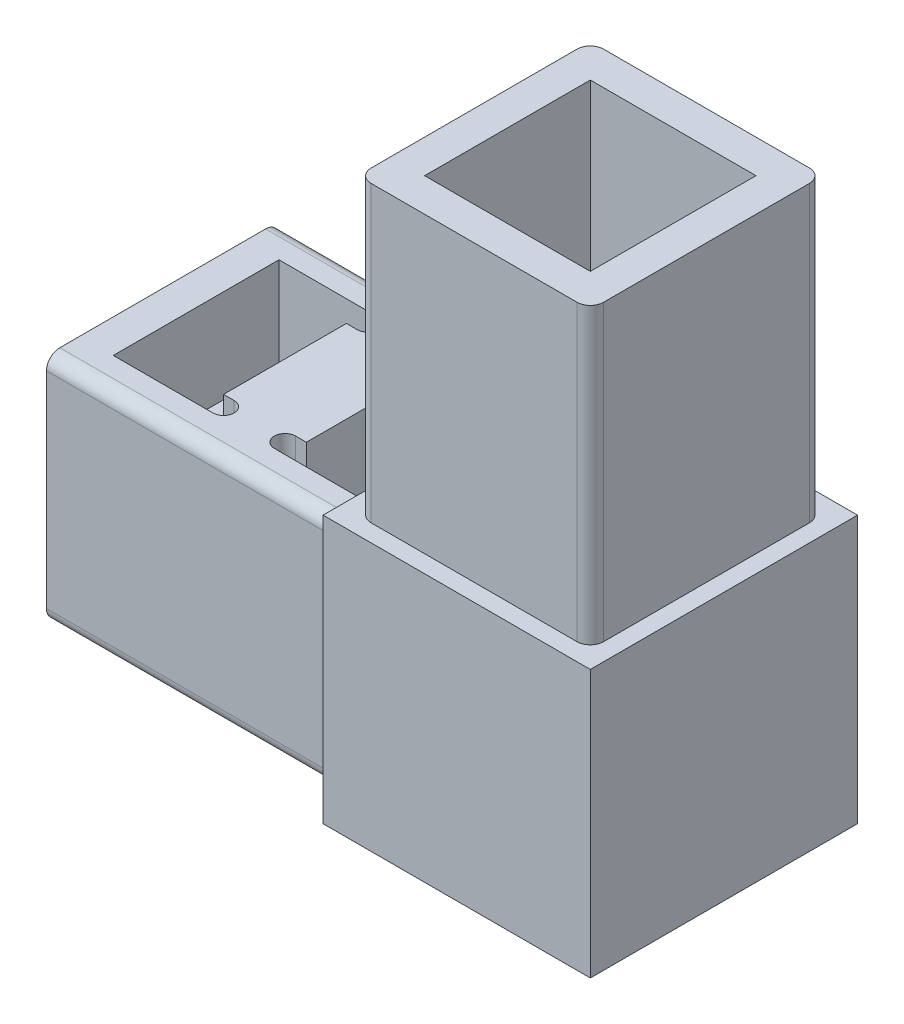
from build123d import *

# Parameters (mm, degrees)
SKETCH1_W           = 25.4
SKETCH1_H           = 22.098
BOSS_EXTRUDE1_DEPTH = 1.651
SKETCH2_W           = 53.34
SKETCH2_H           = 22.098
BOSS_EXTRUDE2_DEPTH = 22.098
SKETCH3_W           = 25.4
SKETCH3_H           = 22.098
BOSS_EXTRUDE3_DEPTH = 1.651
SKETCH4_W           = 25.4
SKETCH4_H           = 25.4
BOSS_EXTRUDE4_DEPTH = 1.651
SKETCH5_W           = 25.4
SKETCH5_H           = 25.4
BOSS_EXTRUDE5_DEPTH = 1.651
CUT_EXTRUDE1_DEPTH  = 8.89
CUT_EXTRUDE2_DEPTH  = 8.89
CUT_EXTRUDE3_DEPTH  = 8.89
CUT_EXTRUDE4_DEPTH  = 8.89
SKETCH10_W          = 22.098
SKETCH10_H          = 22.098
BOSS_EXTRUDE6_DEPTH = 27.94
SKETCH11_W          = 15.748
SKETCH11_H          = 15.748
CUT_EXTRUDE5_DEPTH  = 27.94
FILLET1_R           = 1.27


with BuildPart() as part:
    # Sketch1 → Boss-Extrude1 (new body)
    with BuildSketch(Plane(origin=(0, 0, -12.7), x_dir=(-1, 0, 0), z_dir=(0, 0, -1))):
        Rectangle(SKETCH1_W, SKETCH1_H)
    extrude(amount=-BOSS_EXTRUDE1_DEPTH)

    # Sketch2 → Boss-Extrude2 (add)
    with BuildSketch(Plane.XY.offset(-11.049)):
        with Locations((-13.97, 0)):
            Rectangle(SKETCH2_W, SKETCH2_H)
    extrude(amount=BOSS_EXTRUDE2_DEPTH)

    # Sketch3 → Boss-Extrude3 (add)
    with BuildSketch(Plane.XY.offset(11.049)):
        Rectangle(SKETCH3_W, SKETCH3_H)
    extrude(amount=BOSS_EXTRUDE3_DEPTH)

    # Sketch4 → Boss-Extrude4 (add)
    with BuildSketch(Plane(origin=(0, 11.049, 0), x_dir=(-1, 0, 0), z_dir=(0, 1, 0))):
        Rectangle(SKETCH4_W, SKETCH4_H)
    extrude(amount=BOSS_EXTRUDE4_DEPTH)

    # Sketch5 → Boss-Extrude5 (add)
    with BuildSketch(Plane.XZ.offset(11.049)):
        Rectangle(SKETCH5_W, SKETCH5_H)
    extrude(amount=BOSS_EXTRUDE5_DEPTH)

    # Sketch6 → Cut-Extrude1 (cut)
    with BuildSketch(Plane(origin=(0, 11.049, 0), x_dir=(-1, 0, 0), z_dir=(0, 1, 0))):
        with BuildLine():
            Line((21.1455, 5.842), (22.1615, 5.842))
            ThreePointArc((22.1615, 5.842), (23.1775, 6.858), (22.1615, 7.874))
            Line((22.1615, 7.874), (12.7, 7.874))
            Line((12.7, 7.874), (12.7, -7.874))
            Line((12.7, -7.874), (22.1615, -7.874))
            ThreePointArc((22.1615, -7.874), (23.1775, -6.858), (22.1615, -5.842))
            Line((22.1615, -5.842), (21.1455, -5.842))
            Line((21.1455, -5.842), (21.1455, 5.842))
        make_face()
    extrude(amount=-CUT_EXTRUDE1_DEPTH, mode=Mode.SUBTRACT)

    # Sketch7 → Cut-Extrude2 (cut)
    with BuildSketch(Plane.XZ.offset(11.049)):
        with BuildLine():
            Line((-22.1615, 5.842), (-21.1455, 5.842))
            Line((-21.1455, 5.842), (-21.1455, -5.842))
            Line((-21.1455, -5.842), (-22.1615, -5.842))
            ThreePointArc((-22.1615, -5.842), (-23.1775, -6.858), (-22.1615, -7.874))
            Line((-22.1615, -7.874), (-12.7, -7.874))
            Line((-12.7, -7.874), (-12.7, 7.874))
            Line((-12.7, 7.874), (-22.1615, 7.874))
            ThreePointArc((-22.1615, 7.874), (-23.1775, 6.858), (-22.1615, 5.842))
        make_face()
    extrude(amount=-CUT_EXTRUDE2_DEPTH, mode=Mode.SUBTRACT)

    # Sketch8 → Cut-Extrude3 (cut)
    with BuildSketch(Plane(origin=(0, 11.049, 0), x_dir=(-1, 0, 0), z_dir=(0, 1, 0))):
        with BuildLine():
            Line((28.0035, -7.874), (37.465, -7.874))
            Line((37.465, -7.874), (37.465, 7.874))
            Line((37.465, 7.874), (28.0035, 7.874))
            ThreePointArc((28.0035, 7.874), (26.9875, 6.858), (28.0035, 5.842))
            Line((28.0035, 5.842), (29.0195, 5.842))
            Line((29.0195, 5.842), (29.0195, -5.842))
            Line((29.0195, -5.842), (28.0035, -5.842))
            ThreePointArc((28.0035, -5.842), (26.9875, -6.858), (28.0035, -7.874))
        make_face()
    extrude(amount=-CUT_EXTRUDE3_DEPTH, mode=Mode.SUBTRACT)

    # Sketch9 → Cut-Extrude4 (cut)
    with BuildSketch(Plane.XZ.offset(11.049)):
        with BuildLine():
            Line((-37.465, 7.874), (-37.465, -7.874))
            Line((-37.465, -7.874), (-28.0035, -7.874))
            ThreePointArc((-28.0035, -7.874), (-26.9875, -6.858), (-28.0035, -5.842))
            Line((-28.0035, -5.842), (-29.0195, -5.842))
            Line((-29.0195, -5.842), (-29.0195, 5.842))
            Line((-29.0195, 5.842), (-28.0035, 5.842))
            ThreePointArc((-28.0035, 5.842), (-26.9875, 6.858), (-28.0035, 7.874))
            Line((-28.0035, 7.874), (-37.465, 7.874))
        make_face()
    extrude(amount=-CUT_EXTRUDE4_DEPTH, mode=Mode.SUBTRACT)

    # Sketch10 → Boss-Extrude6 (add)
    with BuildSketch(Plane(origin=(0, 12.7, 0), x_dir=(-1, 0, 0), z_dir=(0, 1, 0))):
        Rectangle(SKETCH10_W, SKETCH10_H)
    extrude(amount=BOSS_EXTRUDE6_DEPTH)

    # Sketch11 → Cut-Extrude5 (cut)
    with BuildSketch(Plane(origin=(0, 40.64, 0), x_dir=(-1, 0, 0), z_dir=(0, 1, 0))):
        Rectangle(SKETCH11_W, SKETCH11_H)
    extrude(amount=-CUT_EXTRUDE5_DEPTH, mode=Mode.SUBTRACT)

    # Fillet1
    fillet1_edges = [part.edges().sort_by_distance(p)[0] for p in [
        (-26.67, 11.049, -11.049),
        (-26.67, -11.049, -11.049),
        (-26.67, -11.049, 11.049),
        (-11.049, 26.67, -11.049),
        (-11.049, 26.67, 11.049),
        (11.049, 26.67, 11.049),
        (11.049, 26.67, -11.049),
        (-26.67, 11.049, 11.049),
    ]]
    fillet(fillet1_edges, radius=FILLET1_R)


solid = part.part
